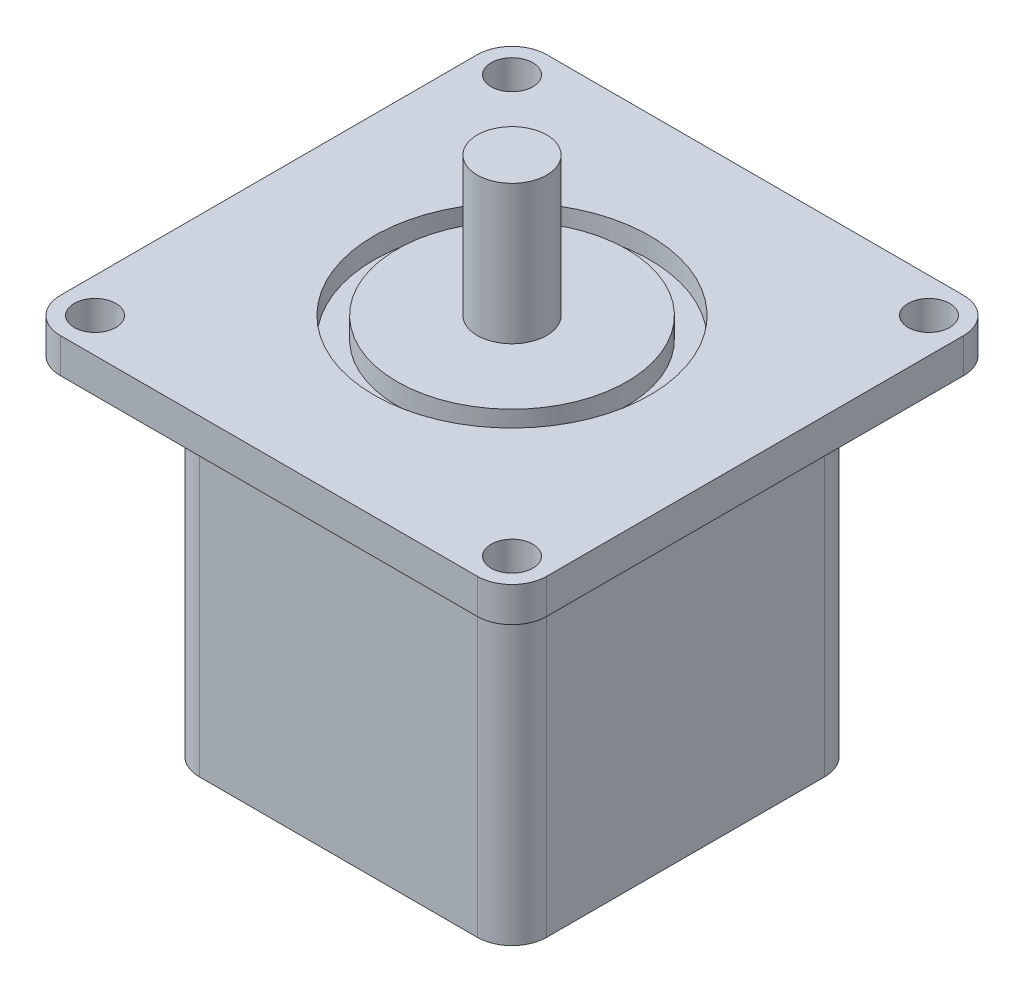
from build123d import *

# Parameters (mm, degrees)
SKETCH1_W           = 50
SKETCH1_H           = 50
BOSS_EXTRUDE1_DEPTH = 50
SKETCH2_W           = 70
SKETCH2_H           = 70
SKETCH2_R           = 3
BOSS_EXTRUDE2_DEPTH = 5
FILLET1_R           = 5
FILLET2_R           = 5
SKETCH3_R           = 19.851731711
SKETCH3_R_2         = 16.528882373
CUT_EXTRUDE1_DEPTH  = 3
SKETCH4_R           = 5
BOSS_EXTRUDE3_DEPTH = 20


with BuildPart() as part:
    # Sketch1 → Boss-Extrude1 (new body)
    with BuildSketch(Plane(origin=(0, 0, 0), x_dir=(1, 0, 0), z_dir=(0, 1, 0))):
        Rectangle(SKETCH1_W, SKETCH1_H)
    extrude(amount=BOSS_EXTRUDE1_DEPTH)

    # Sketch2 → Boss-Extrude2 (add)
    with BuildSketch(Plane(origin=(0, 50, 0), x_dir=(1, 0, 0), z_dir=(0, 1, 0))):
        Rectangle(SKETCH2_W, SKETCH2_H)
        with Locations((-30, 30)):
            Circle(SKETCH2_R, mode=Mode.SUBTRACT)
        with Locations((30, 30)):
            Circle(SKETCH2_R, mode=Mode.SUBTRACT)
        with Locations((-30, -30)):
            Circle(SKETCH2_R, mode=Mode.SUBTRACT)
        with Locations((30, -30)):
            Circle(SKETCH2_R, mode=Mode.SUBTRACT)
    extrude(amount=BOSS_EXTRUDE2_DEPTH)

    # Fillet1
    fillet1_edges = [part.edges().sort_by_distance(p)[0] for p in [
        (25, 25, 25),
        (-25, 25, 25),
        (-25, 25, -25),
        (25, 25, -25),
    ]]
    fillet(fillet1_edges, radius=FILLET1_R)

    # Fillet2
    fillet2_edges = [part.edges().sort_by_distance(p)[0] for p in [
        (35, 52.5, 35),
        (35, 52.5, -35),
        (-35, 52.5, -35),
        (-35, 52.5, 35),
    ]]
    fillet(fillet2_edges, radius=FILLET2_R)

    # Sketch3 → Cut-Extrude1 (cut)
    with BuildSketch(Plane(origin=(0, 55, 0), x_dir=(1, 0, 0), z_dir=(0, 1, 0))):
        Circle(SKETCH3_R)
        Circle(SKETCH3_R_2, mode=Mode.SUBTRACT)
    extrude(amount=-CUT_EXTRUDE1_DEPTH, mode=Mode.SUBTRACT)

    # Sketch4 → Boss-Extrude3 (add)
    with BuildSketch(Plane(origin=(0, 55, 0), x_dir=(1, 0, 0), z_dir=(0, 1, 0))):
        Circle(SKETCH4_R)
    extrude(amount=BOSS_EXTRUDE3_DEPTH)


solid = part.part
